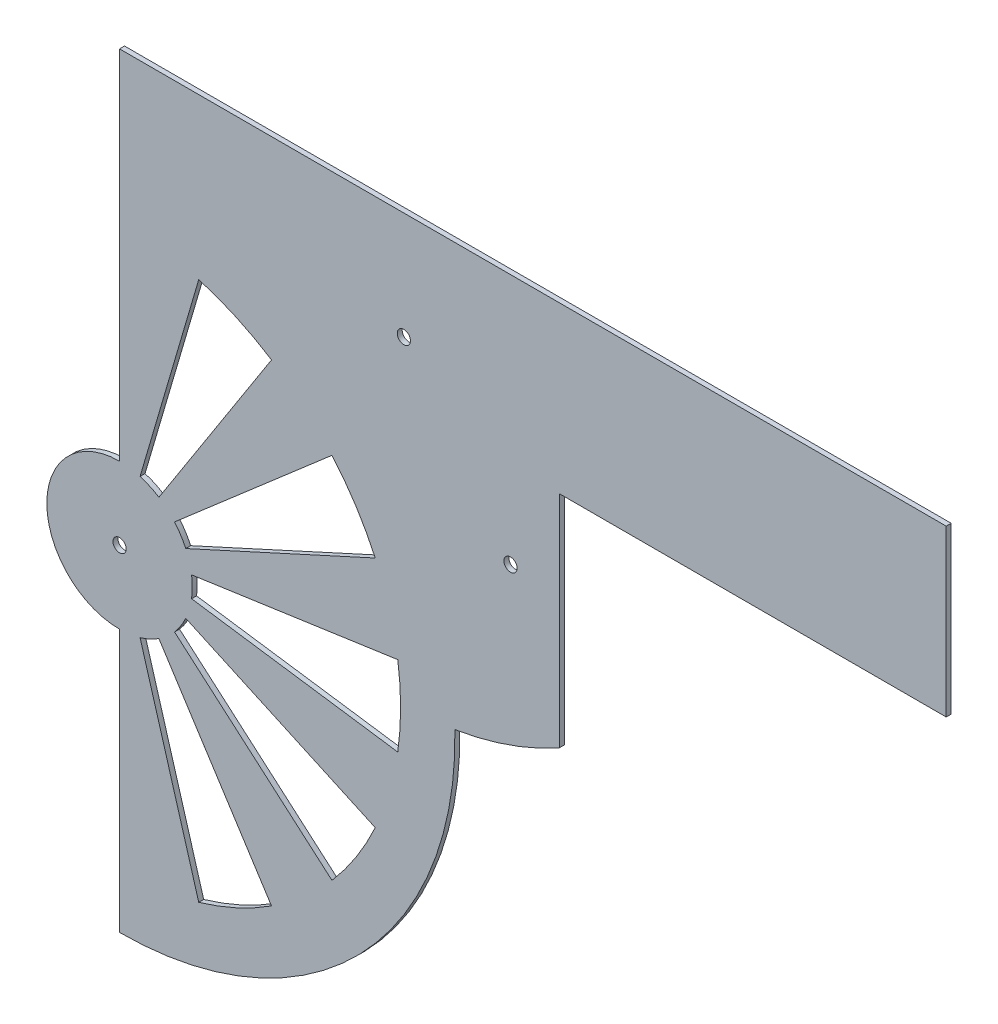
from build123d import *

# Parameters (mm, degrees)
SKETCH1_R           = 2
BOSS_EXTRUDE1_DEPTH = 1.5
CUT_EXTRUDE1_DEPTH  = 2.5


with BuildPart() as part:
    # Sketch1 → Boss-Extrude1 (new body)
    with BuildSketch(Plane.XY):
        with BuildLine():
            Line((0, 130), (0, 22))
            ThreePointArc((0, 22), (-22, 0), (0, -22))
            Line((0, -22), (0, -101.426173946))
            ThreePointArc((0, -101.426173946), (72.567414345, -70.860702344), (101.397454872, 2.413484395))
            ThreePointArc((101.397454872, 2.413484395), (117.671962719, 6.534414164), (132.983960448, 13.418046445))
            Line((132.983960448, 13.418046445), (132.983960448, 80))
            Line((132.983960448, 80), (250, 80))
            Line((250, 80), (250, 130))
            Line((250, 130), (0, 130))
        make_face()
        Circle(SKETCH1_R, mode=Mode.SUBTRACT)
        with Locations((85.977020164, 97.508727834)):
            Circle(SKETCH1_R, mode=Mode.SUBTRACT)
        with Locations((118.232097827, 54.047858824)):
            Circle(SKETCH1_R, mode=Mode.SUBTRACT)
    extrude(amount=BOSS_EXTRUDE1_DEPTH)

    # Sketch2 → Cut-Extrude1 (cut, through all)
    with BuildSketch(Plane.XY.offset(1.5)):
        with BuildLine():
            Line((6.198116251, -21.10884542), (23.947267332, -81.556902757))
            ThreePointArc((23.947267332, -81.556902757), (35.310276105, -77.318719605), (45.954469484, -71.506550291))
            Line((45.954469484, -71.506550291), (11.894097984, -18.507577722))
            ThreePointArc((11.894097984, -18.507577722), (9.139130286, -20.011903898), (6.198116251, -21.10884542))
        make_face()
        with BuildLine():
            Line((16.626490636, -14.406936147), (64.23871382, -55.663162385))
            ThreePointArc((64.23871382, -55.663162385), (71.506550291, -45.954469484), (77.318719605, -35.310276105))
            Line((77.318719605, -35.310276105), (20.011903898, -9.139130286))
            ThreePointArc((20.011903898, -9.139130286), (18.507577722, -11.894097984), (16.626490636, -14.406936147))
        make_face()
        with BuildLine():
            Line((21.776071721, -3.130926442), (84.13482256, -12.096761253))
            ThreePointArc((84.13482256, -12.096761253), (85, 0), (84.13482256, 12.096761253))
            Line((84.13482256, 12.096761253), (21.776071721, 3.130926442))
            ThreePointArc((21.776071721, 3.130926442), (22, 0), (21.776071721, -3.130926442))
        make_face()
        with BuildLine():
            Line((20.011903898, 9.139130286), (77.318719605, 35.310276105))
            ThreePointArc((77.318719605, 35.310276105), (71.506550291, 45.954469484), (64.23871382, 55.663162385))
            Line((64.23871382, 55.663162385), (16.626490636, 14.406936147))
            ThreePointArc((16.626490636, 14.406936147), (18.507577722, 11.894097984), (20.011903898, 9.139130286))
        make_face()
        with BuildLine():
            Line((11.894097984, 18.507577722), (45.954469484, 71.506550291))
            ThreePointArc((45.954469484, 71.506550291), (35.310276105, 77.318719605), (23.947267332, 81.556902757))
            Line((23.947267332, 81.556902757), (6.198116251, 21.10884542))
            ThreePointArc((6.198116251, 21.10884542), (9.139130286, 20.011903898), (11.894097984, 18.507577722))
        make_face()
    extrude(amount=-CUT_EXTRUDE1_DEPTH, mode=Mode.SUBTRACT)


solid = part.part
